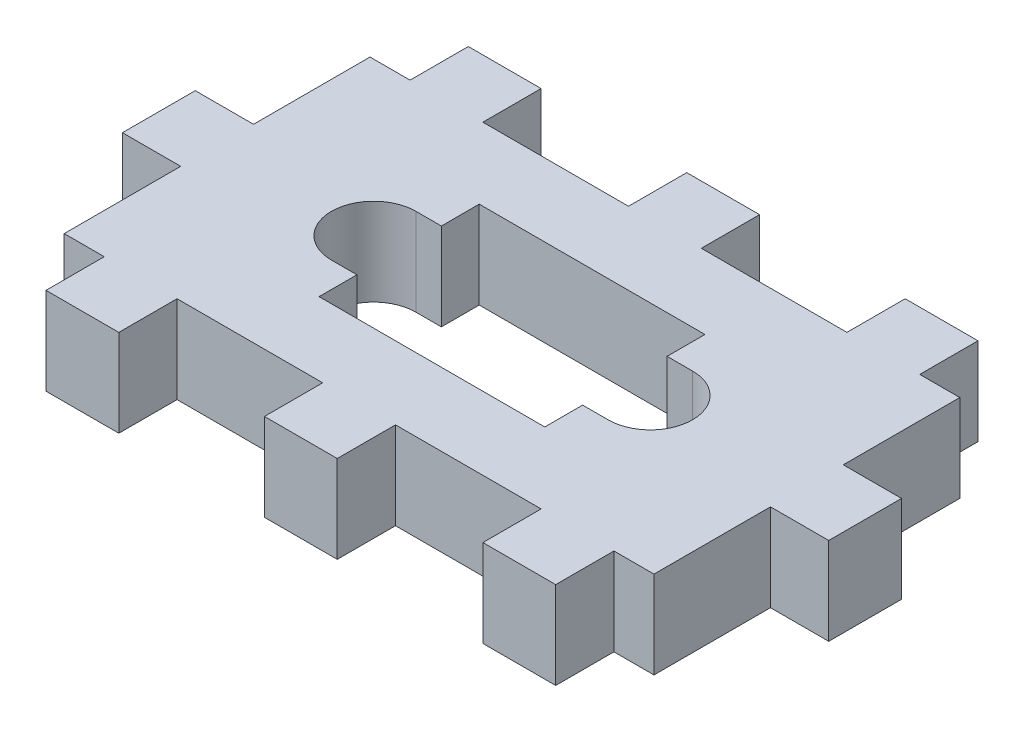
from build123d import *

# Parameters (mm, degrees)
SKETCH1_W           = 15.5
SKETCH1_H           = 11
BOSS_EXTRUDE1_DEPTH = 1.6
BOSS_EXTRUDE2_DEPTH = 1.6
SKETCH3_W           = 40.5
SKETCH3_H           = 21
BOSS_EXTRUDE3_DEPTH = 6
CUT_EXTRUDE1_DEPTH  = 2.6
SKETCH5_W           = 5
SKETCH5_H           = 4
BOSS_EXTRUDE4_DEPTH = 6
LPATTERN1_COUNT     = 2
LPATTERN1_PITCH     = 15
LPATTERN1_COL_COUNT = 2
LPATTERN1_COL_PITCH = 15
SKETCH6_W           = 4
SKETCH6_H           = 5
BOSS_EXTRUDE5_DEPTH = 6


with BuildPart() as part:
    # Sketch1 → Boss-Extrude1 (new body)
    with BuildSketch(Plane(origin=(0, 0, 0), x_dir=(1, 0, 0), z_dir=(0, 1, 0))):
        with Locations((7.75, -5.5)):
            Rectangle(SKETCH1_W, SKETCH1_H)
    extrude(amount=BOSS_EXTRUDE1_DEPTH)

    # Sketch2 → Boss-Extrude2 (add, through all)
    with BuildSketch(Plane(origin=(0, 1.6, 0), x_dir=(1, 0, 0), z_dir=(0, 1, 0))):
        with BuildLine():
            Line((-1.75, -4), (-1.75, -2.6))
            ThreePointArc((-1.75, -2.6), (-4.65, -5.5), (-1.75, -8.4))
            Line((-1.75, -8.4), (-1.75, -7))
            ThreePointArc((-1.75, -7), (-3.25, -5.5), (-1.75, -4))
        make_face()
        with BuildLine():
            ThreePointArc((0, -3.187533784), (-0.827002716, -2.750804479), (-1.75, -2.6))
            Line((-1.75, -2.6), (-1.75, -4))
            ThreePointArc((-1.75, -4), (-0.689339828, -4.439339828), (-0.25, -5.5))
            ThreePointArc((-0.25, -5.5), (-0.689339828, -6.560660172), (-1.75, -7))
            Line((-1.75, -7), (-1.75, -8.4))
            ThreePointArc((-1.75, -8.4), (-0.827002716, -8.249195521), (0, -7.812466216))
            Line((0, -7.812466216), (0, -3.187533784))
        make_face()
        with BuildLine():
            Line((0, -2.6), (-1.75, -2.6))
            ThreePointArc((-1.75, -2.6), (-0.827002716, -2.750804479), (0, -3.187533784))
            Line((0, -3.187533784), (0, -2.6))
        make_face()
        with BuildLine():
            ThreePointArc((0, -7.812466216), (-0.827002716, -8.249195521), (-1.75, -8.4))
            Line((-1.75, -8.4), (0, -8.4))
            Line((0, -8.4), (0, -7.812466216))
        make_face()
        with BuildLine():
            ThreePointArc((20.15, -5.5), (19.300609665, -3.449390335), (17.25, -2.6))
            Line((17.25, -2.6), (17.25, -4))
            ThreePointArc((17.25, -4), (18.310660172, -4.439339828), (18.75, -5.5))
            ThreePointArc((18.75, -5.5), (18.310660172, -6.560660172), (17.25, -7))
            Line((17.25, -7), (17.25, -8.4))
            ThreePointArc((17.25, -8.4), (19.300609665, -7.550609665), (20.15, -5.5))
        make_face()
        with BuildLine():
            Line((17.25, -4), (17.25, -2.6))
            ThreePointArc((17.25, -2.6), (16.327002716, -2.750804479), (15.5, -3.187533784))
            Line((15.5, -3.187533784), (15.5, -7.812466216))
            ThreePointArc((15.5, -7.812466216), (16.327002716, -8.249195521), (17.25, -8.4))
            Line((17.25, -8.4), (17.25, -7))
            ThreePointArc((17.25, -7), (15.75, -5.5), (17.25, -4))
        make_face()
        with BuildLine():
            Line((17.25, -2.6), (15.5, -2.6))
            Line((15.5, -2.6), (15.5, -3.187533784))
            ThreePointArc((15.5, -3.187533784), (16.327002716, -2.750804479), (17.25, -2.6))
        make_face()
        with BuildLine():
            Line((15.5, -7.812466216), (15.5, -8.4))
            Line((15.5, -8.4), (17.25, -8.4))
            ThreePointArc((17.25, -8.4), (16.327002716, -8.249195521), (15.5, -7.812466216))
        make_face()
    extrude(amount=-BOSS_EXTRUDE2_DEPTH)

    # Sketch4 → Cut-Extrude1 (cut, through all)
    with BuildSketch(Plane(origin=(0, 1.6, 0), x_dir=(1, 0, 0), z_dir=(0, 1, 0))):
        with BuildLine():
            Line((0, 0), (0, -2.6))
            Line((0, -2.6), (-1.75, -2.6))
            ThreePointArc((-1.75, -2.6), (-4.65, -5.5), (-1.75, -8.4))
            Line((-1.75, -8.4), (0, -8.4))
            Line((0, -8.4), (0, -11))
            Line((0, -11), (15.5, -11))
            Line((15.5, -11), (15.5, -8.4))
            Line((15.5, -8.4), (17.25, -8.4))
            ThreePointArc((17.25, -8.4), (20.15, -5.5), (17.25, -2.6))
            Line((17.25, -2.6), (15.5, -2.6))
            Line((15.5, -2.6), (15.5, 0))
            Line((15.5, 0), (0, 0))
        make_face()
    extrude(amount=-CUT_EXTRUDE1_DEPTH, mode=Mode.SUBTRACT)


with BuildPart() as body_2:
    # Sketch3 → Boss-Extrude3 (new body)
    with BuildSketch(Plane(origin=(0, 1.6, 0), x_dir=(1, 0, 0), z_dir=(0, 1, 0))):
        with Locations((7.75, -5.5)):
            Rectangle(SKETCH3_W, SKETCH3_H)
        with BuildLine():
            Line((0, 0), (0, -2.6))
            Line((0, -2.6), (-1.75, -2.6))
            ThreePointArc((-1.75, -2.6), (-4.65, -5.5), (-1.75, -8.4))
            Line((-1.75, -8.4), (0, -8.4))
            Line((0, -8.4), (0, -11))
            Line((0, -11), (15.5, -11))
            Line((15.5, -11), (15.5, -8.4))
            Line((15.5, -8.4), (17.25, -8.4))
            ThreePointArc((17.25, -8.4), (20.15, -5.5), (17.25, -2.6))
            Line((17.25, -2.6), (15.5, -2.6))
            Line((15.5, -2.6), (15.5, 0))
            Line((15.5, 0), (0, 0))
        make_face(mode=Mode.SUBTRACT)
    extrude(amount=BOSS_EXTRUDE3_DEPTH)

    # Sketch5 → Boss-Extrude4 (add, through all)
    with BuildSketch(Plane(origin=(0, 7.6, 0), x_dir=(1, 0, 0), z_dir=(0, 1, 0))):
        with Locations((7.75, 7)):
            Rectangle(SKETCH5_W, SKETCH5_H)
        with Locations((7.75, -18)):
            Rectangle(SKETCH5_W, SKETCH5_H)
    boss_extrude4 = extrude(amount=-BOSS_EXTRUDE4_DEPTH)

    # LPattern1: Boss-Extrude4 ×2
    with Locations(*[(i * LPATTERN1_PITCH, 0, 0) for i in range(1, LPATTERN1_COUNT)]):
        add(boss_extrude4)

    # LPattern1 col: Boss-Extrude4 ×2
    with Locations(*[(-i * LPATTERN1_COL_PITCH, 0, 0) for i in range(1, LPATTERN1_COL_COUNT)]):
        add(boss_extrude4)

    # Sketch6 → Boss-Extrude5 (add, through all)
    with BuildSketch(Plane(origin=(0, 7.6, 0), x_dir=(1, 0, 0), z_dir=(0, 1, 0))):
        with Locations((-14.5, -5.5)):
            Rectangle(SKETCH6_W, SKETCH6_H)
        with Locations((30, -5.5)):
            Rectangle(SKETCH6_W, SKETCH6_H)
    extrude(amount=-BOSS_EXTRUDE5_DEPTH)


solid = body_2.part
